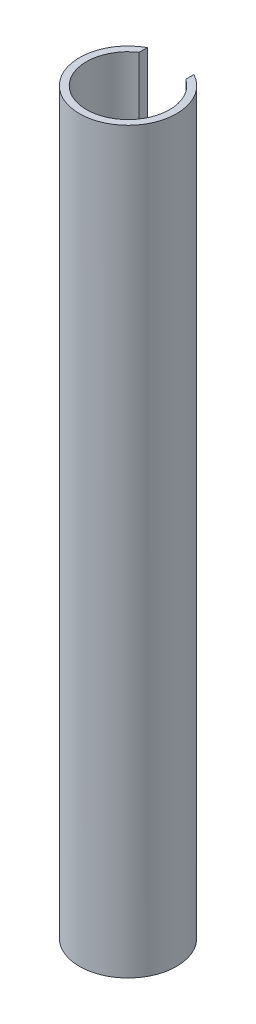
from build123d import *

# Parameters (mm, degrees)
SKETCH_1_R          = 12.5
SKETCH_1_R_2        = 10.7
EXTRUDE_1_DEPTH     = 190
SKETCH_3_W          = 12
SKETCH_3_H          = 4.814393821
CUT_EXTRUDE_1_DEPTH = 50


with BuildPart() as part:
    # Эскиз1 → Бобышка-Вытянуть1 (new body)
    with BuildSketch(Plane(origin=(0, 0, 0), x_dir=(1, 0, 0), z_dir=(0, 1, 0))):
        Circle(SKETCH_1_R)
        Circle(SKETCH_1_R_2, mode=Mode.SUBTRACT)
    extrude(amount=EXTRUDE_1_DEPTH)

    # Эскиз3 → Вырез-Вытянуть1 (cut)
    with BuildSketch(Plane(origin=(0, 190, 0), x_dir=(1, 0, 0), z_dir=(0, 1, 0))):
        with Locations((0, 10.407196911)):
            Rectangle(SKETCH_3_W, SKETCH_3_H)
    extrude(amount=-CUT_EXTRUDE_1_DEPTH, mode=Mode.SUBTRACT)


solid = part.part
